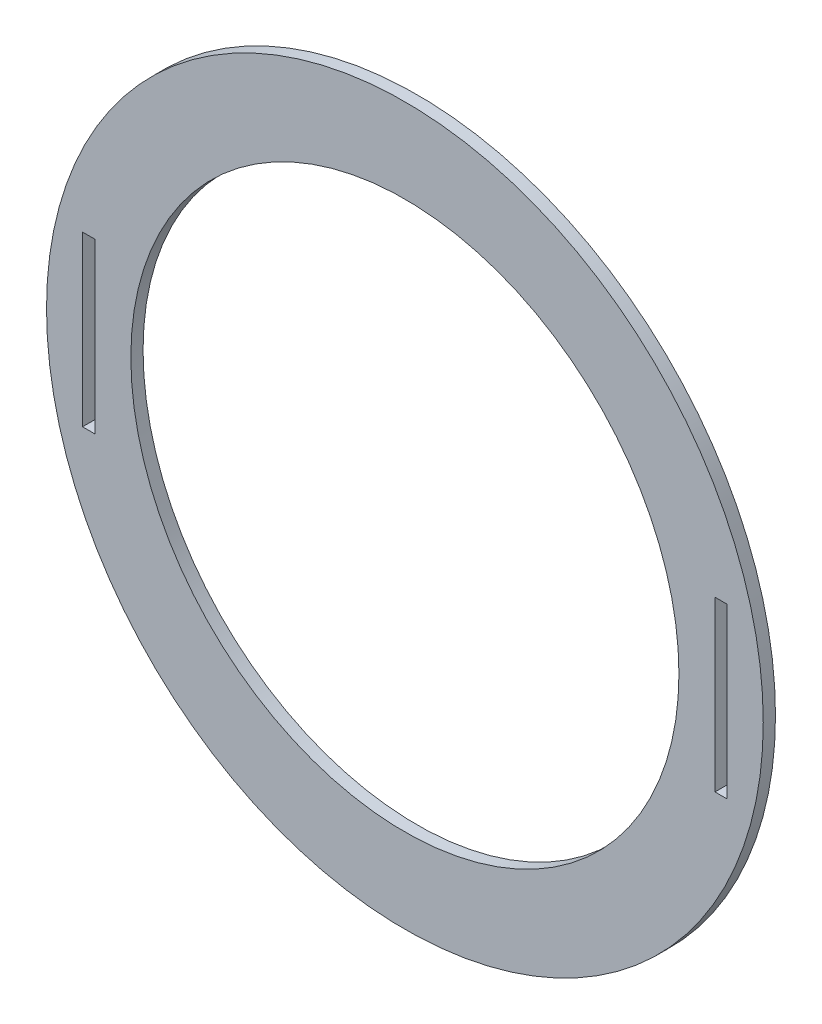
from build123d import *

# Parameters (mm, degrees)
SKETCH1_R           = 85
SKETCH1_R_2         = 65
SKETCH1_W           = 2.9
SKETCH1_H           = 40
BOSS_EXTRUDE1_DEPTH = 2.9


with BuildPart() as part:
    # Sketch1 → Boss-Extrude1 (new body)
    with BuildSketch(Plane.XY):
        Circle(SKETCH1_R)
        Circle(SKETCH1_R_2, mode=Mode.SUBTRACT)
        with Locations((-75, 0)):
            Rectangle(SKETCH1_W, SKETCH1_H, mode=Mode.SUBTRACT)
        with Locations((75, 0)):
            Rectangle(SKETCH1_W, SKETCH1_H, mode=Mode.SUBTRACT)
    extrude(amount=BOSS_EXTRUDE1_DEPTH)


solid = part.part
